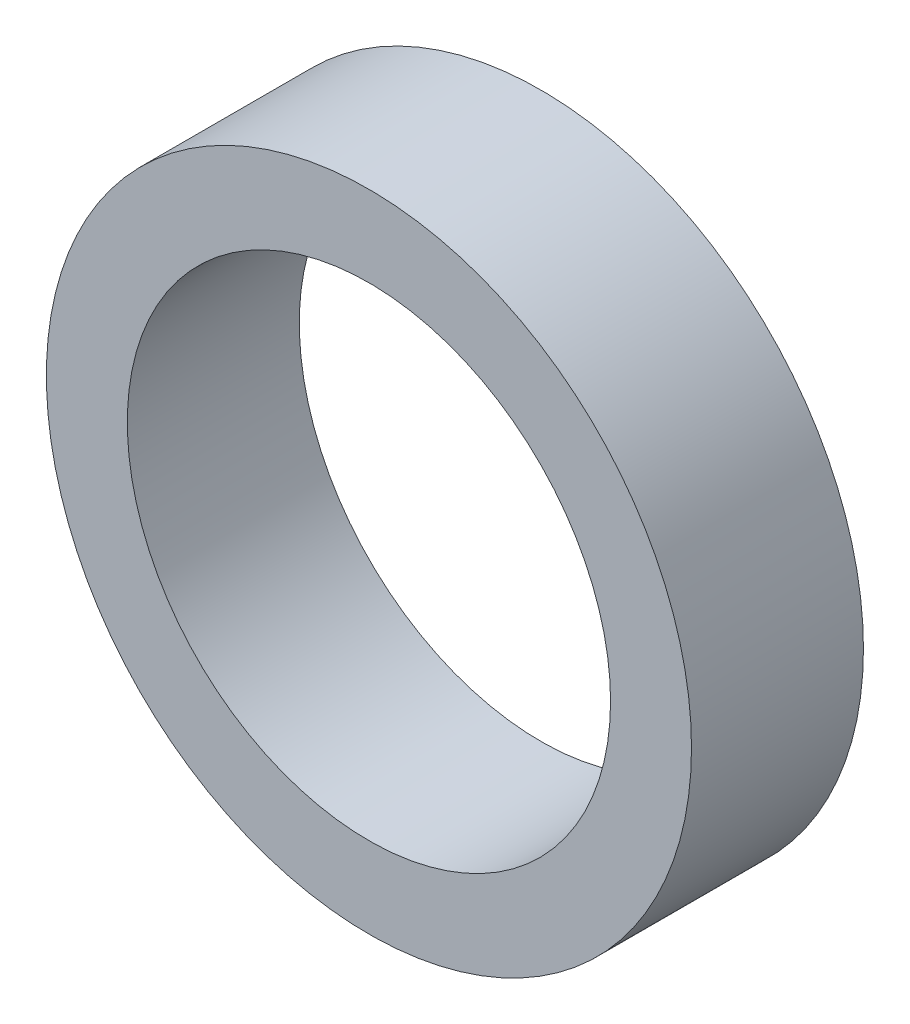
from build123d import *

# Parameters (mm, degrees)
SKIZZE1_R                       = 37.521428571
SKIZZE1_R_2                     = 28.105528142
AUFSATZ_LINEAR_AUSTRAGEN1_DEPTH = 20


with BuildPart() as part:
    # Skizze1 → Aufsatz-Linear austragen1 (new body)
    with BuildSketch(Plane.XY):
        Circle(SKIZZE1_R)
        Circle(SKIZZE1_R_2, mode=Mode.SUBTRACT)
    extrude(amount=AUFSATZ_LINEAR_AUSTRAGEN1_DEPTH)


solid = part.part
